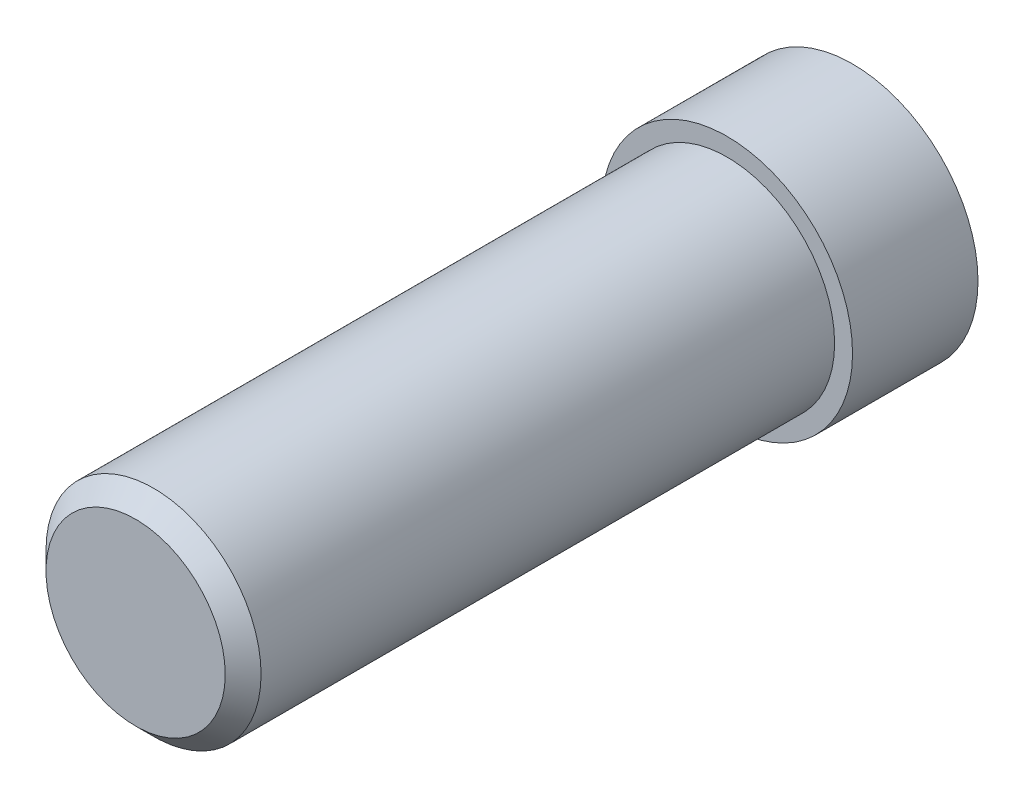
from build123d import *

# Parameters (mm, degrees)
SKETCH1_R           = 7
BOSS_EXTRUDE1_DEPTH = 7
SKETCH2_R           = 6
BOSS_EXTRUDE2_DEPTH = 33
CHAMFER1_SIZE       = 1


with BuildPart() as part:
    # Sketch1 → Boss-Extrude1 (new body)
    with BuildSketch(Plane.XY):
        Circle(SKETCH1_R)
    extrude(amount=BOSS_EXTRUDE1_DEPTH)

    # Sketch2 → Boss-Extrude2 (add)
    with BuildSketch(Plane.XY.offset(7)):
        Circle(SKETCH2_R)
    extrude(amount=BOSS_EXTRUDE2_DEPTH)

    # Chamfer1
    chamfer1_edges = [part.edges().sort_by_distance(p)[0] for p in [
        (-6, 0, 40),
    ]]
    chamfer(chamfer1_edges, length=CHAMFER1_SIZE)


solid = part.part
